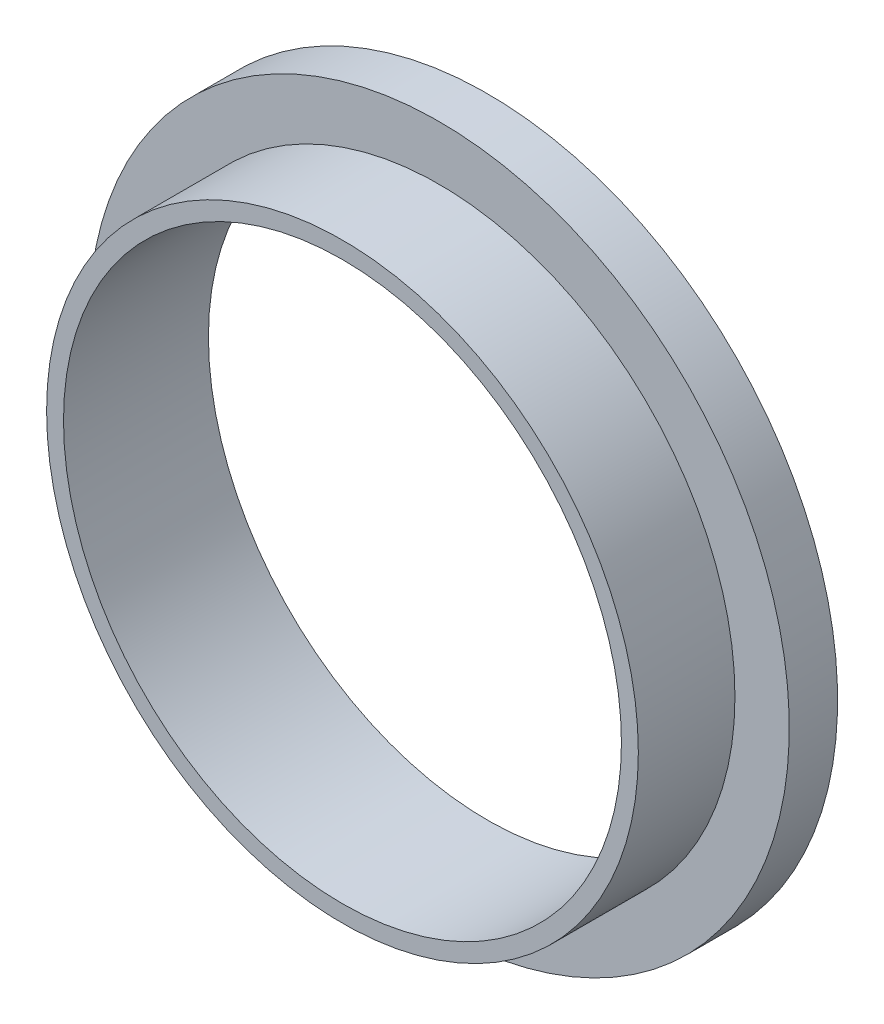
from build123d import *

# Parameters (mm, degrees)
CROQUIS1_R              = 12.25
SALIENTE_EXTRUIR1_DEPTH = 4
CROQUIS2_R              = 14.5
SALIENTE_EXTRUIR2_DEPTH = 2
CROQUIS3_R              = 11.55
CORTAR_EXTRUIR1_DEPTH   = 10


with BuildPart() as part:
    # Croquis1 → Saliente-Extruir1 (new body)
    with BuildSketch(Plane.XY):
        Circle(CROQUIS1_R)
    extrude(amount=SALIENTE_EXTRUIR1_DEPTH)

    # Croquis2 → Saliente-Extruir2 (add)
    with BuildSketch(Plane(origin=(0, 0, 0), x_dir=(-1, 0, 0), z_dir=(0, 0, -1))):
        Circle(CROQUIS2_R)
    extrude(amount=SALIENTE_EXTRUIR2_DEPTH)

    # Croquis3 → Cortar-Extruir1 (cut)
    with BuildSketch(Plane(origin=(0, 0, -2), x_dir=(-1, 0, 0), z_dir=(0, 0, -1))):
        Circle(CROQUIS3_R)
    extrude(amount=-CORTAR_EXTRUIR1_DEPTH, mode=Mode.SUBTRACT)


solid = part.part
